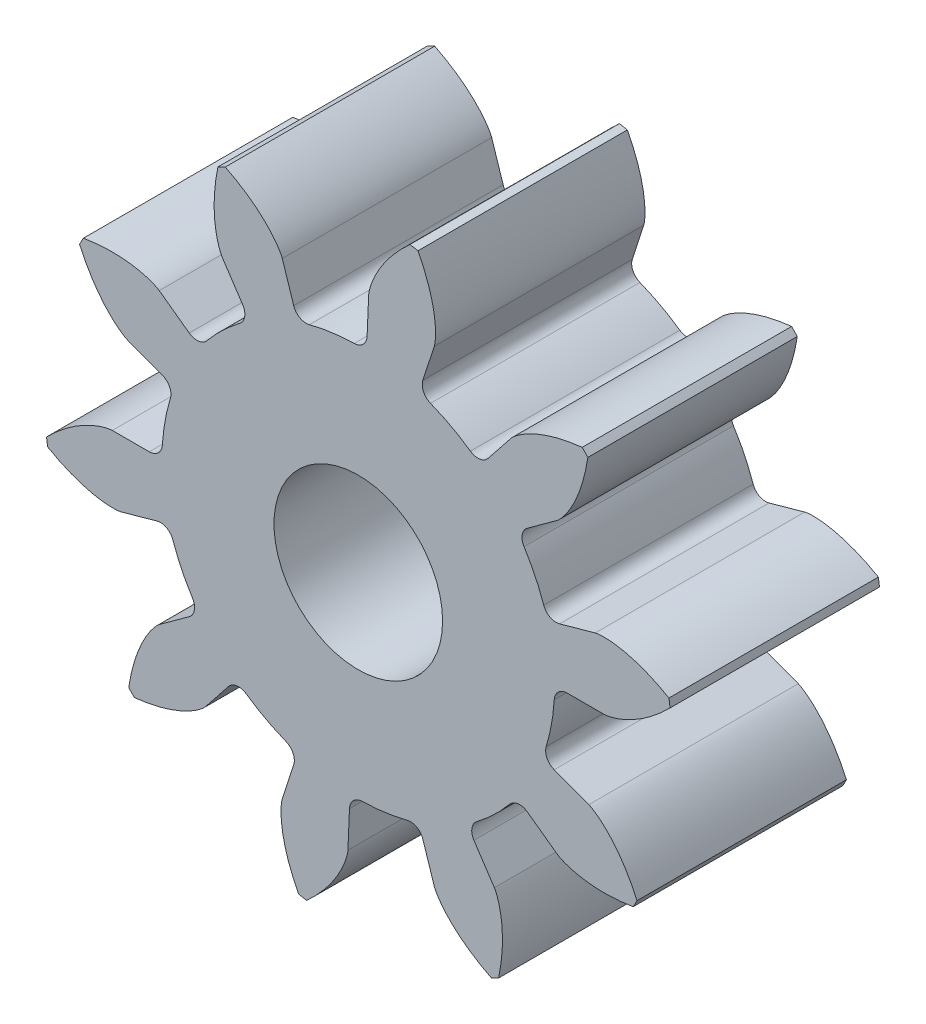
from build123d import *

# Parameters (mm, degrees)
BOSS_EXTRUDE3_DEPTH      = 10
FILLET1_R                = 0.625
CIRPATTERN8_COUNT        = 10
CIRPATTERN8_COPY_1_DEPTH = 10
CIRPATTERN8_COPY_2_DEPTH = 10
CIRPATTERN8_COPY_3_DEPTH = 10
CIRPATTERN8_COPY_4_DEPTH = 10
CIRPATTERN8_COPY_5_DEPTH = 10
CIRPATTERN8_COPY_6_DEPTH = 10
CIRPATTERN8_COPY_7_DEPTH = 10
CIRPATTERN8_COPY_8_DEPTH = 10
CIRPATTERN8_COPY_9_DEPTH = 10
FILLET1_OF_CIRPATTERN8_R = 0.625
SKETCH3_R                = 4.025
CUT_EXTRUDE2_DEPTH       = 11.0000001


with BuildPart() as part:
    # Sketch1 → Boss-Extrude3 (new body)
    with BuildSketch(Plane.XY):
        with BuildLine():
            Line((9.375, 0), (11.74615776, 0))
            add(Edge.make_bspline(
                [(11.74615776, 0), (11.754841732, 0.000183768), (11.779179169, 0.001267888), (11.825088632, 0.005562117), (11.899691958, 0.015746104), (11.994171849, 0.033372696), (12.115394291, 0.0614606), (12.256834487, 0.101322639), (12.410572757, 0.152161687), (12.575722813, 0.214972968), (12.738406771, 0.284201046), (12.898564829, 0.359289485), (13.056063732, 0.439482048), (13.244229139, 0.542891509), (13.466087479, 0.675556037), (13.719390719, 0.842943905), (13.999170912, 1.047118123), (14.275580492, 1.270025494), (14.531397244, 1.493742481), (14.716666587, 1.670363519), (14.8331519, 1.786067897), (14.886668048, 1.84041148)],
                knots=[0, 0, 0, 0, 0, 0.005376748, 0.015083688, 0.02853182, 0.046610139, 0.064854849, 0.092110525, 0.119476175, 0.146842495, 0.174208853, 0.201574955, 0.228941013, 0.256307345, 0.307035032, 0.361767351, 0.41649966, 0.471231936, 0.525964281, 0.573449371, 0.573449371, 0.573449371, 0.573449371, 0.573449371], degree=4))
            ThreePointArc((14.886668048, 1.84041148), (14.874411346, 1.936978864), (14.861528233, 2.033464676))
            Line((14.861528233, 2.033464676), (9.288455145, 1.270915423))
            ThreePointArc((9.288455145, 1.270915423), (9.353338762, 0.636929357), (9.375, 0))
        make_face()
        with BuildLine():
            ThreePointArc((-9.288455145, -1.270915423), (0.636929357, -9.353338762), (9.375, 0))
            ThreePointArc((9.375, 0), (9.353338762, 0.636929357), (9.288455145, 1.270915423))
            Line((9.288455145, 1.270915423), (-9.288455145, -1.270915423))
        make_face()
        with BuildLine():
            Line((-9.288455145, -1.270915423), (9.288455145, 1.270915423))
            ThreePointArc((9.288455145, 1.270915423), (-1.270915423, 9.288455145), (-9.288455145, -1.270915423))
        make_face()
    boss_extrude3 = extrude(amount=BOSS_EXTRUDE3_DEPTH)

    # Mirror2: Boss-Extrude3 across plane
    add(boss_extrude3.mirror(Plane(origin=(0, 0, 10), x_dir=(0, 0, 1), z_dir=(0.135564312, -0.990768549, 0))))

    # Fillet1
    fillet1_edges = [part.edges().sort_by_distance(p)[0] for p in [
        (9.375, 0, 5),
        (9.030418451, 2.518366058, 5),
    ]]
    fillet(fillet1_edges, radius=FILLET1_R)

    # CirPattern8: Boss-Extrude3 ×10 about axis
    cirpattern8_axis = Axis((0, 0, 10), (0, 0, -1))
    for i in range(1, CIRPATTERN8_COUNT):
        add(boss_extrude3.rotate(cirpattern8_axis, i * 360 / CIRPATTERN8_COUNT))

    # CirPattern8 copy 1 sketch → CirPattern8 copy 1 (add)
    with BuildSketch(Plane(origin=(0, 0, 0), x_dir=(0.937175512, -0.348858224, 0), z_dir=(0, 0, 1))):
        with BuildLine():
            Line((9.375, 0), (11.74615776, 0))
            add(Edge.make_bspline(
                [(11.74615776, 0), (11.754841732, -0.000183768), (11.779179169, -0.001267888), (11.825088632, -0.005562117), (11.899691958, -0.015746104), (11.994171849, -0.033372696), (12.115394291, -0.0614606), (12.256834487, -0.101322639), (12.410572757, -0.152161687), (12.575722813, -0.214972968), (12.738406771, -0.284201046), (12.898564829, -0.359289485), (13.056063732, -0.439482048), (13.244229139, -0.542891509), (13.466087479, -0.675556037), (13.719390719, -0.842943905), (13.999170912, -1.047118123), (14.275580492, -1.270025494), (14.531397244, -1.493742481), (14.716666587, -1.670363519), (14.8331519, -1.786067897), (14.886668048, -1.84041148)],
                knots=[0, 0, 0, 0, 0, 0.005376748, 0.015083688, 0.02853182, 0.046610139, 0.064854849, 0.092110525, 0.119476175, 0.146842495, 0.174208853, 0.201574955, 0.228941013, 0.256307345, 0.307035032, 0.361767351, 0.41649966, 0.471231936, 0.525964281, 0.573449371, 0.573449371, 0.573449371, 0.573449371, 0.573449371], degree=4))
            ThreePointArc((14.886668048, -1.84041148), (14.874411346, -1.936978864), (14.861528233, -2.033464676))
            Line((14.861528233, -2.033464676), (9.288455145, -1.270915423))
            ThreePointArc((9.288455145, -1.270915423), (9.353338762, -0.636929357), (9.375, 0))
        make_face()
        with BuildLine():
            ThreePointArc((-9.288455145, 1.270915423), (0.636929357, 9.353338762), (9.375, 0))
            ThreePointArc((9.375, 0), (9.353338762, -0.636929357), (9.288455145, -1.270915423))
            Line((9.288455145, -1.270915423), (-9.288455145, 1.270915423))
        make_face()
        with BuildLine():
            Line((-9.288455145, 1.270915423), (9.288455145, -1.270915423))
            ThreePointArc((9.288455145, -1.270915423), (-1.270915423, -9.288455145), (-9.288455145, 1.270915423))
        make_face()
    extrude(amount=CIRPATTERN8_COPY_1_DEPTH)

    # CirPattern8 copy 2 sketch → CirPattern8 copy 2 (add)
    with BuildSketch(Plane(origin=(0, 0, 0), x_dir=(0.553137197, -0.833090176, 0), z_dir=(0, 0, 1))):
        with BuildLine():
            Line((9.375, 0), (11.74615776, 0))
            add(Edge.make_bspline(
                [(11.74615776, 0), (11.754841732, -0.000183768), (11.779179169, -0.001267888), (11.825088632, -0.005562117), (11.899691958, -0.015746104), (11.994171849, -0.033372696), (12.115394291, -0.0614606), (12.256834487, -0.101322639), (12.410572757, -0.152161687), (12.575722813, -0.214972968), (12.738406771, -0.284201046), (12.898564829, -0.359289485), (13.056063732, -0.439482048), (13.244229139, -0.542891509), (13.466087479, -0.675556037), (13.719390719, -0.842943905), (13.999170912, -1.047118123), (14.275580492, -1.270025494), (14.531397244, -1.493742481), (14.716666587, -1.670363519), (14.8331519, -1.786067897), (14.886668048, -1.84041148)],
                knots=[0, 0, 0, 0, 0, 0.005376748, 0.015083688, 0.02853182, 0.046610139, 0.064854849, 0.092110525, 0.119476175, 0.146842495, 0.174208853, 0.201574955, 0.228941013, 0.256307345, 0.307035032, 0.361767351, 0.41649966, 0.471231936, 0.525964281, 0.573449371, 0.573449371, 0.573449371, 0.573449371, 0.573449371], degree=4))
            ThreePointArc((14.886668048, -1.84041148), (14.874411346, -1.936978864), (14.861528233, -2.033464676))
            Line((14.861528233, -2.033464676), (9.288455145, -1.270915423))
            ThreePointArc((9.288455145, -1.270915423), (9.353338762, -0.636929357), (9.375, 0))
        make_face()
        with BuildLine():
            ThreePointArc((-9.288455145, 1.270915423), (0.636929357, 9.353338762), (9.375, 0))
            ThreePointArc((9.375, 0), (9.353338762, -0.636929357), (9.288455145, -1.270915423))
            Line((9.288455145, -1.270915423), (-9.288455145, 1.270915423))
        make_face()
        with BuildLine():
            Line((-9.288455145, 1.270915423), (9.288455145, -1.270915423))
            ThreePointArc((9.288455145, -1.270915423), (-1.270915423, -9.288455145), (-9.288455145, 1.270915423))
        make_face()
    extrude(amount=CIRPATTERN8_COPY_2_DEPTH)

    # CirPattern8 copy 3 sketch → CirPattern8 copy 3 (add)
    with BuildSketch(Plane(origin=(0, 0, 0), x_dir=(-0.042180727, -0.999109997, 0), z_dir=(0, 0, 1))):
        with BuildLine():
            Line((9.375, 0), (11.74615776, 0))
            add(Edge.make_bspline(
                [(11.74615776, 0), (11.754841732, -0.000183768), (11.779179169, -0.001267888), (11.825088632, -0.005562117), (11.899691958, -0.015746104), (11.994171849, -0.033372696), (12.115394291, -0.0614606), (12.256834487, -0.101322639), (12.410572757, -0.152161687), (12.575722813, -0.214972968), (12.738406771, -0.284201046), (12.898564829, -0.359289485), (13.056063732, -0.439482048), (13.244229139, -0.542891509), (13.466087479, -0.675556037), (13.719390719, -0.842943905), (13.999170912, -1.047118123), (14.275580492, -1.270025494), (14.531397244, -1.493742481), (14.716666587, -1.670363519), (14.8331519, -1.786067897), (14.886668048, -1.84041148)],
                knots=[0, 0, 0, 0, 0, 0.005376748, 0.015083688, 0.02853182, 0.046610139, 0.064854849, 0.092110525, 0.119476175, 0.146842495, 0.174208853, 0.201574955, 0.228941013, 0.256307345, 0.307035032, 0.361767351, 0.41649966, 0.471231936, 0.525964281, 0.573449371, 0.573449371, 0.573449371, 0.573449371, 0.573449371], degree=4))
            ThreePointArc((14.886668048, -1.84041148), (14.874411346, -1.936978864), (14.861528233, -2.033464676))
            Line((14.861528233, -2.033464676), (9.288455145, -1.270915423))
            ThreePointArc((9.288455145, -1.270915423), (9.353338762, -0.636929357), (9.375, 0))
        make_face()
        with BuildLine():
            ThreePointArc((-9.288455145, 1.270915423), (0.636929357, 9.353338762), (9.375, 0))
            ThreePointArc((9.375, 0), (9.353338762, -0.636929357), (9.288455145, -1.270915423))
            Line((9.288455145, -1.270915423), (-9.288455145, 1.270915423))
        make_face()
        with BuildLine():
            Line((-9.288455145, 1.270915423), (9.288455145, -1.270915423))
            ThreePointArc((9.288455145, -1.270915423), (-1.270915423, -9.288455145), (-9.288455145, 1.270915423))
        make_face()
    extrude(amount=CIRPATTERN8_COPY_3_DEPTH)

    # CirPattern8 copy 4 sketch → CirPattern8 copy 4 (add)
    with BuildSketch(Plane(origin=(0, 0, 0), x_dir=(-0.621387047, -0.783503757, 0), z_dir=(0, 0, 1))):
        with BuildLine():
            Line((9.375, 0), (11.74615776, 0))
            add(Edge.make_bspline(
                [(11.74615776, 0), (11.754841732, -0.000183768), (11.779179169, -0.001267888), (11.825088632, -0.005562117), (11.899691958, -0.015746104), (11.994171849, -0.033372696), (12.115394291, -0.0614606), (12.256834487, -0.101322639), (12.410572757, -0.152161687), (12.575722813, -0.214972968), (12.738406771, -0.284201046), (12.898564829, -0.359289485), (13.056063732, -0.439482048), (13.244229139, -0.542891509), (13.466087479, -0.675556037), (13.719390719, -0.842943905), (13.999170912, -1.047118123), (14.275580492, -1.270025494), (14.531397244, -1.493742481), (14.716666587, -1.670363519), (14.8331519, -1.786067897), (14.886668048, -1.84041148)],
                knots=[0, 0, 0, 0, 0, 0.005376748, 0.015083688, 0.02853182, 0.046610139, 0.064854849, 0.092110525, 0.119476175, 0.146842495, 0.174208853, 0.201574955, 0.228941013, 0.256307345, 0.307035032, 0.361767351, 0.41649966, 0.471231936, 0.525964281, 0.573449371, 0.573449371, 0.573449371, 0.573449371, 0.573449371], degree=4))
            ThreePointArc((14.886668048, -1.84041148), (14.874411346, -1.936978864), (14.861528233, -2.033464676))
            Line((14.861528233, -2.033464676), (9.288455145, -1.270915423))
            ThreePointArc((9.288455145, -1.270915423), (9.353338762, -0.636929357), (9.375, 0))
        make_face()
        with BuildLine():
            ThreePointArc((-9.288455145, 1.270915423), (0.636929357, 9.353338762), (9.375, 0))
            ThreePointArc((9.375, 0), (9.353338762, -0.636929357), (9.288455145, -1.270915423))
            Line((9.288455145, -1.270915423), (-9.288455145, 1.270915423))
        make_face()
        with BuildLine():
            Line((-9.288455145, 1.270915423), (9.288455145, -1.270915423))
            ThreePointArc((9.288455145, -1.270915423), (-1.270915423, -9.288455145), (-9.288455145, 1.270915423))
        make_face()
    extrude(amount=CIRPATTERN8_COPY_4_DEPTH)

    # CirPattern8 copy 5 sketch → CirPattern8 copy 5 (add)
    with BuildSketch(Plane(origin=(0, 0, 0), x_dir=(-0.963244635, -0.268625713, 0), z_dir=(0, 0, 1))):
        with BuildLine():
            Line((9.375, 0), (11.74615776, 0))
            add(Edge.make_bspline(
                [(11.74615776, 0), (11.754841732, -0.000183768), (11.779179169, -0.001267888), (11.825088632, -0.005562117), (11.899691958, -0.015746104), (11.994171849, -0.033372696), (12.115394291, -0.0614606), (12.256834487, -0.101322639), (12.410572757, -0.152161687), (12.575722813, -0.214972968), (12.738406771, -0.284201046), (12.898564829, -0.359289485), (13.056063732, -0.439482048), (13.244229139, -0.542891509), (13.466087479, -0.675556037), (13.719390719, -0.842943905), (13.999170912, -1.047118123), (14.275580492, -1.270025494), (14.531397244, -1.493742481), (14.716666587, -1.670363519), (14.8331519, -1.786067897), (14.886668048, -1.84041148)],
                knots=[0, 0, 0, 0, 0, 0.005376748, 0.015083688, 0.02853182, 0.046610139, 0.064854849, 0.092110525, 0.119476175, 0.146842495, 0.174208853, 0.201574955, 0.228941013, 0.256307345, 0.307035032, 0.361767351, 0.41649966, 0.471231936, 0.525964281, 0.573449371, 0.573449371, 0.573449371, 0.573449371, 0.573449371], degree=4))
            ThreePointArc((14.886668048, -1.84041148), (14.874411346, -1.936978864), (14.861528233, -2.033464676))
            Line((14.861528233, -2.033464676), (9.288455145, -1.270915423))
            ThreePointArc((9.288455145, -1.270915423), (9.353338762, -0.636929357), (9.375, 0))
        make_face()
        with BuildLine():
            ThreePointArc((-9.288455145, 1.270915423), (0.636929357, 9.353338762), (9.375, 0))
            ThreePointArc((9.375, 0), (9.353338762, -0.636929357), (9.288455145, -1.270915423))
            Line((9.288455145, -1.270915423), (-9.288455145, 1.270915423))
        make_face()
        with BuildLine():
            Line((-9.288455145, 1.270915423), (9.288455145, -1.270915423))
            ThreePointArc((9.288455145, -1.270915423), (-1.270915423, -9.288455145), (-9.288455145, 1.270915423))
        make_face()
    extrude(amount=CIRPATTERN8_COPY_5_DEPTH)

    # CirPattern8 copy 6 sketch → CirPattern8 copy 6 (add)
    with BuildSketch(Plane(origin=(0, 0, 0), x_dir=(-0.937175512, 0.348858224, 0), z_dir=(0, 0, 1))):
        with BuildLine():
            Line((9.375, 0), (11.74615776, 0))
            add(Edge.make_bspline(
                [(11.74615776, 0), (11.754841732, -0.000183768), (11.779179169, -0.001267888), (11.825088632, -0.005562117), (11.899691958, -0.015746104), (11.994171849, -0.033372696), (12.115394291, -0.0614606), (12.256834487, -0.101322639), (12.410572757, -0.152161687), (12.575722813, -0.214972968), (12.738406771, -0.284201046), (12.898564829, -0.359289485), (13.056063732, -0.439482048), (13.244229139, -0.542891509), (13.466087479, -0.675556037), (13.719390719, -0.842943905), (13.999170912, -1.047118123), (14.275580492, -1.270025494), (14.531397244, -1.493742481), (14.716666587, -1.670363519), (14.8331519, -1.786067897), (14.886668048, -1.84041148)],
                knots=[0, 0, 0, 0, 0, 0.005376748, 0.015083688, 0.02853182, 0.046610139, 0.064854849, 0.092110525, 0.119476175, 0.146842495, 0.174208853, 0.201574955, 0.228941013, 0.256307345, 0.307035032, 0.361767351, 0.41649966, 0.471231936, 0.525964281, 0.573449371, 0.573449371, 0.573449371, 0.573449371, 0.573449371], degree=4))
            ThreePointArc((14.886668048, -1.84041148), (14.874411346, -1.936978864), (14.861528233, -2.033464676))
            Line((14.861528233, -2.033464676), (9.288455145, -1.270915423))
            ThreePointArc((9.288455145, -1.270915423), (9.353338762, -0.636929357), (9.375, 0))
        make_face()
        with BuildLine():
            ThreePointArc((-9.288455145, 1.270915423), (0.636929357, 9.353338762), (9.375, 0))
            ThreePointArc((9.375, 0), (9.353338762, -0.636929357), (9.288455145, -1.270915423))
            Line((9.288455145, -1.270915423), (-9.288455145, 1.270915423))
        make_face()
        with BuildLine():
            Line((-9.288455145, 1.270915423), (9.288455145, -1.270915423))
            ThreePointArc((9.288455145, -1.270915423), (-1.270915423, -9.288455145), (-9.288455145, 1.270915423))
        make_face()
    extrude(amount=CIRPATTERN8_COPY_6_DEPTH)

    # CirPattern8 copy 7 sketch → CirPattern8 copy 7 (add)
    with BuildSketch(Plane(origin=(0, 0, 0), x_dir=(-0.553137197, 0.833090176, 0), z_dir=(0, 0, 1))):
        with BuildLine():
            Line((9.375, 0), (11.74615776, 0))
            add(Edge.make_bspline(
                [(11.74615776, 0), (11.754841732, -0.000183768), (11.779179169, -0.001267888), (11.825088632, -0.005562117), (11.899691958, -0.015746104), (11.994171849, -0.033372696), (12.115394291, -0.0614606), (12.256834487, -0.101322639), (12.410572757, -0.152161687), (12.575722813, -0.214972968), (12.738406771, -0.284201046), (12.898564829, -0.359289485), (13.056063732, -0.439482048), (13.244229139, -0.542891509), (13.466087479, -0.675556037), (13.719390719, -0.842943905), (13.999170912, -1.047118123), (14.275580492, -1.270025494), (14.531397244, -1.493742481), (14.716666587, -1.670363519), (14.8331519, -1.786067897), (14.886668048, -1.84041148)],
                knots=[0, 0, 0, 0, 0, 0.005376748, 0.015083688, 0.02853182, 0.046610139, 0.064854849, 0.092110525, 0.119476175, 0.146842495, 0.174208853, 0.201574955, 0.228941013, 0.256307345, 0.307035032, 0.361767351, 0.41649966, 0.471231936, 0.525964281, 0.573449371, 0.573449371, 0.573449371, 0.573449371, 0.573449371], degree=4))
            ThreePointArc((14.886668048, -1.84041148), (14.874411346, -1.936978864), (14.861528233, -2.033464676))
            Line((14.861528233, -2.033464676), (9.288455145, -1.270915423))
            ThreePointArc((9.288455145, -1.270915423), (9.353338762, -0.636929357), (9.375, 0))
        make_face()
        with BuildLine():
            ThreePointArc((-9.288455145, 1.270915423), (0.636929357, 9.353338762), (9.375, 0))
            ThreePointArc((9.375, 0), (9.353338762, -0.636929357), (9.288455145, -1.270915423))
            Line((9.288455145, -1.270915423), (-9.288455145, 1.270915423))
        make_face()
        with BuildLine():
            Line((-9.288455145, 1.270915423), (9.288455145, -1.270915423))
            ThreePointArc((9.288455145, -1.270915423), (-1.270915423, -9.288455145), (-9.288455145, 1.270915423))
        make_face()
    extrude(amount=CIRPATTERN8_COPY_7_DEPTH)

    # CirPattern8 copy 8 sketch → CirPattern8 copy 8 (add)
    with BuildSketch(Plane(origin=(0, 0, 0), x_dir=(0.042180727, 0.999109997, 0), z_dir=(0, 0, 1))):
        with BuildLine():
            Line((9.375, 0), (11.74615776, 0))
            add(Edge.make_bspline(
                [(11.74615776, 0), (11.754841732, -0.000183768), (11.779179169, -0.001267888), (11.825088632, -0.005562117), (11.899691958, -0.015746104), (11.994171849, -0.033372696), (12.115394291, -0.0614606), (12.256834487, -0.101322639), (12.410572757, -0.152161687), (12.575722813, -0.214972968), (12.738406771, -0.284201046), (12.898564829, -0.359289485), (13.056063732, -0.439482048), (13.244229139, -0.542891509), (13.466087479, -0.675556037), (13.719390719, -0.842943905), (13.999170912, -1.047118123), (14.275580492, -1.270025494), (14.531397244, -1.493742481), (14.716666587, -1.670363519), (14.8331519, -1.786067897), (14.886668048, -1.84041148)],
                knots=[0, 0, 0, 0, 0, 0.005376748, 0.015083688, 0.02853182, 0.046610139, 0.064854849, 0.092110525, 0.119476175, 0.146842495, 0.174208853, 0.201574955, 0.228941013, 0.256307345, 0.307035032, 0.361767351, 0.41649966, 0.471231936, 0.525964281, 0.573449371, 0.573449371, 0.573449371, 0.573449371, 0.573449371], degree=4))
            ThreePointArc((14.886668048, -1.84041148), (14.874411346, -1.936978864), (14.861528233, -2.033464676))
            Line((14.861528233, -2.033464676), (9.288455145, -1.270915423))
            ThreePointArc((9.288455145, -1.270915423), (9.353338762, -0.636929357), (9.375, 0))
        make_face()
        with BuildLine():
            ThreePointArc((-9.288455145, 1.270915423), (0.636929357, 9.353338762), (9.375, 0))
            ThreePointArc((9.375, 0), (9.353338762, -0.636929357), (9.288455145, -1.270915423))
            Line((9.288455145, -1.270915423), (-9.288455145, 1.270915423))
        make_face()
        with BuildLine():
            Line((-9.288455145, 1.270915423), (9.288455145, -1.270915423))
            ThreePointArc((9.288455145, -1.270915423), (-1.270915423, -9.288455145), (-9.288455145, 1.270915423))
        make_face()
    extrude(amount=CIRPATTERN8_COPY_8_DEPTH)

    # CirPattern8 copy 9 sketch → CirPattern8 copy 9 (add)
    with BuildSketch(Plane(origin=(0, 0, 0), x_dir=(0.621387047, 0.783503757, 0), z_dir=(0, 0, 1))):
        with BuildLine():
            Line((9.375, 0), (11.74615776, 0))
            add(Edge.make_bspline(
                [(11.74615776, 0), (11.754841732, -0.000183768), (11.779179169, -0.001267888), (11.825088632, -0.005562117), (11.899691958, -0.015746104), (11.994171849, -0.033372696), (12.115394291, -0.0614606), (12.256834487, -0.101322639), (12.410572757, -0.152161687), (12.575722813, -0.214972968), (12.738406771, -0.284201046), (12.898564829, -0.359289485), (13.056063732, -0.439482048), (13.244229139, -0.542891509), (13.466087479, -0.675556037), (13.719390719, -0.842943905), (13.999170912, -1.047118123), (14.275580492, -1.270025494), (14.531397244, -1.493742481), (14.716666587, -1.670363519), (14.8331519, -1.786067897), (14.886668048, -1.84041148)],
                knots=[0, 0, 0, 0, 0, 0.005376748, 0.015083688, 0.02853182, 0.046610139, 0.064854849, 0.092110525, 0.119476175, 0.146842495, 0.174208853, 0.201574955, 0.228941013, 0.256307345, 0.307035032, 0.361767351, 0.41649966, 0.471231936, 0.525964281, 0.573449371, 0.573449371, 0.573449371, 0.573449371, 0.573449371], degree=4))
            ThreePointArc((14.886668048, -1.84041148), (14.874411346, -1.936978864), (14.861528233, -2.033464676))
            Line((14.861528233, -2.033464676), (9.288455145, -1.270915423))
            ThreePointArc((9.288455145, -1.270915423), (9.353338762, -0.636929357), (9.375, 0))
        make_face()
        with BuildLine():
            ThreePointArc((-9.288455145, 1.270915423), (0.636929357, 9.353338762), (9.375, 0))
            ThreePointArc((9.375, 0), (9.353338762, -0.636929357), (9.288455145, -1.270915423))
            Line((9.288455145, -1.270915423), (-9.288455145, 1.270915423))
        make_face()
        with BuildLine():
            Line((-9.288455145, 1.270915423), (9.288455145, -1.270915423))
            ThreePointArc((9.288455145, -1.270915423), (-1.270915423, -9.288455145), (-9.288455145, 1.270915423))
        make_face()
    extrude(amount=CIRPATTERN8_COPY_9_DEPTH)

    # Fillet1 of CirPattern8
    fillet1_of_cirpattern8_edges = [part.edges().sort_by_distance(p)[0] for p in [
        (7.584534322, -5.51048674, 5),
        (8.786020422, -3.270545849, 5),
        (2.897034322, -8.91615484, 5),
        (5.185661217, -7.810220403, 5),
        (-2.897034322, -8.91615484, 5),
        (-0.395444318, -9.366656223, 5),
        (-7.584534322, -5.51048674, 5),
        (-5.825503564, -7.345347726, 5),
        (-9.375, 0, 5),
        (-9.030418451, -2.518366058, 5),
        (-7.584534322, 5.51048674, 5),
        (-8.786020422, 3.270545849, 5),
        (-2.897034322, 8.91615484, 5),
        (-5.185661217, 7.810220403, 5),
        (2.897034322, 8.91615484, 5),
        (0.395444318, 9.366656223, 5),
        (7.584534322, 5.51048674, 5),
        (5.825503564, 7.345347726, 5),
    ]]
    fillet(fillet1_of_cirpattern8_edges, radius=FILLET1_OF_CIRPATTERN8_R)

    # Sketch3 → Cut-Extrude2 (cut, through all)
    with BuildSketch(Plane.XY.offset(10)):
        Circle(SKETCH3_R)
    extrude(amount=-CUT_EXTRUDE2_DEPTH, mode=Mode.SUBTRACT)


solid = part.part
